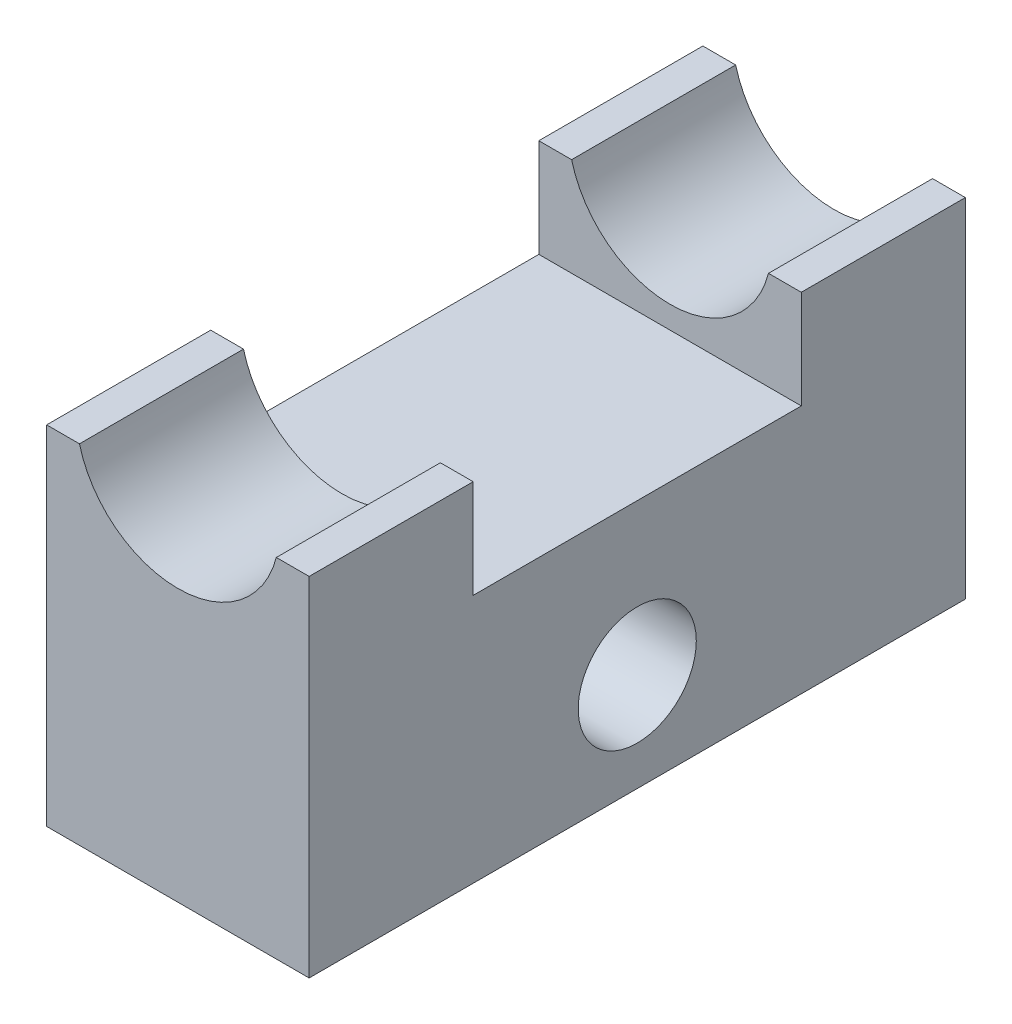
from build123d import *

# Parameters (mm, degrees)
BOSS_EXTRU_1_DEPTH      = 100
ESQUISSE2_R             = 9
ESQUISSE2_W             = 50
ESQUISSE2_H             = 15
ENL_V_MAT_EXTRU_1_DEPTH = 100


with BuildPart() as part:
    # Esquisse1 → Boss.-Extru.1 (new body)
    with BuildSketch(Plane.XY):
        with BuildLine():
            Line((1005.392443992, 375.619056085), (1000.392443992, 375.619056085))
            Line((1000.392443992, 375.619056085), (1000.392443992, 322.619056085))
            Line((1000.392443992, 322.619056085), (1040.392443992, 322.619056085))
            Line((1040.392443992, 322.619056085), (1040.392443992, 375.619056085))
            Line((1040.392443992, 375.619056085), (1035.392443992, 375.619056085))
            ThreePointArc((1035.392443992, 375.619056085), (1020.392443992, 364.024180923), (1005.392443992, 375.619056085))
        make_face()
    extrude(amount=BOSS_EXTRU_1_DEPTH)

    # Esquisse2 → Enlèv. mat.-Extru.1 (cut)
    with BuildSketch(Plane(origin=(1040.392443992, 0, 0), x_dir=(0, 0, -1), z_dir=(1, 0, 0))):
        with Locations((-50, 337.619056085)):
            Circle(ESQUISSE2_R)
        with Locations((-50, 368.119056085)):
            Rectangle(ESQUISSE2_W, ESQUISSE2_H)
    extrude(amount=-ENL_V_MAT_EXTRU_1_DEPTH, mode=Mode.SUBTRACT)


solid = part.part
